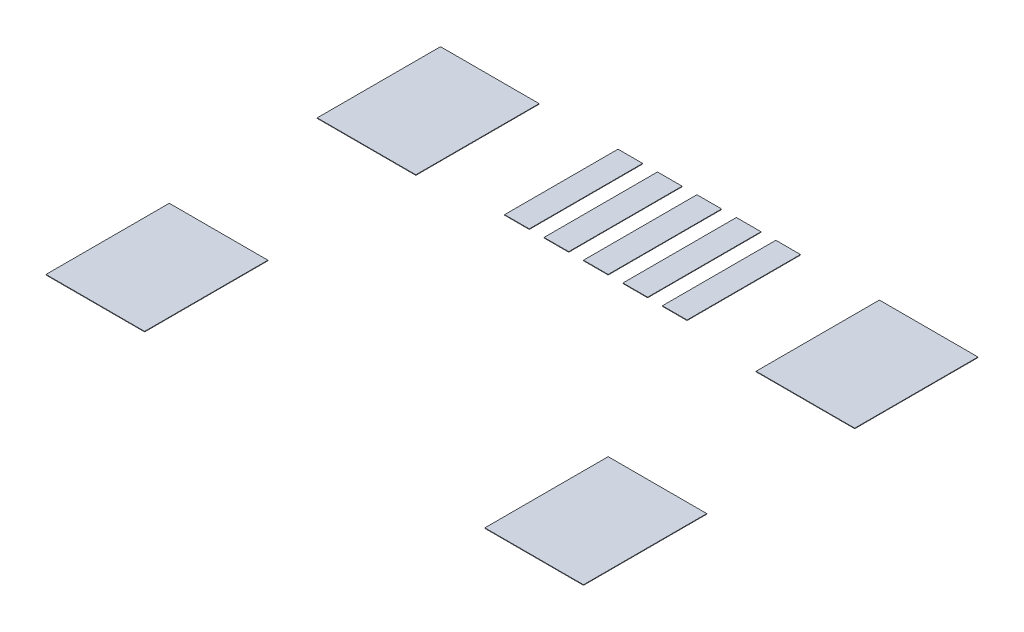
from build123d import *

# Parameters (mm, degrees)
SKETCH1_W             = 2
SKETCH1_H             = 2.5
BOSS_EXTRUDE1_DEPTH   = 0.01
BOSS_EXTRUDE1_2_DEPTH = 0.01
BOSS_EXTRUDE1_3_DEPTH = 0.01
BOSS_EXTRUDE1_4_DEPTH = 0.01
SKETCH1_W_2           = 0.5
SKETCH1_H_2           = 2.3
BOSS_EXTRUDE1_5_DEPTH = 0.01
BOSS_EXTRUDE1_6_DEPTH = 0.01
BOSS_EXTRUDE1_7_DEPTH = 0.01
BOSS_EXTRUDE1_8_DEPTH = 0.01
BOSS_EXTRUDE1_9_DEPTH = 0.01


with BuildPart() as part:
    # Sketch1 → Boss-Extrude1 (new body)
    with BuildSketch(Plane(origin=(0, 0, 0), x_dir=(1, 0, 0), z_dir=(0, 1, 0))):
        with Locations((-4.45, 6.75)):
            Rectangle(SKETCH1_W, SKETCH1_H)
    extrude(amount=-BOSS_EXTRUDE1_DEPTH)


with BuildPart() as body_2:
    # Sketch1 → Boss-Extrude1 2 (new body)
    with BuildSketch(Plane(origin=(0, 0, 0), x_dir=(1, 0, 0), z_dir=(0, 1, 0))):
        with Locations((-4.45, 1.25)):
            Rectangle(SKETCH1_W, SKETCH1_H)
    extrude(amount=-BOSS_EXTRUDE1_2_DEPTH)


with BuildPart() as body_3:
    # Sketch1 → Boss-Extrude1 3 (new body)
    with BuildSketch(Plane(origin=(0, 0, 0), x_dir=(1, 0, 0), z_dir=(0, 1, 0))):
        with Locations((4.45, 6.75)):
            Rectangle(SKETCH1_W, SKETCH1_H)
    extrude(amount=-BOSS_EXTRUDE1_3_DEPTH)


with BuildPart() as body_4:
    # Sketch1 → Boss-Extrude1 4 (new body)
    with BuildSketch(Plane(origin=(0, 0, 0), x_dir=(1, 0, 0), z_dir=(0, 1, 0))):
        with Locations((4.45, 1.25)):
            Rectangle(SKETCH1_W, SKETCH1_H)
    extrude(amount=-BOSS_EXTRUDE1_4_DEPTH)


with BuildPart() as body_5:
    # Sketch1 → Boss-Extrude1 5 (new body)
    with BuildSketch(Plane(origin=(0, 0, 0), x_dir=(1, 0, 0), z_dir=(0, 1, 0))):
        with Locations((-1.6, 6.85)):
            Rectangle(SKETCH1_W_2, SKETCH1_H_2)
    extrude(amount=-BOSS_EXTRUDE1_5_DEPTH)


with BuildPart() as body_6:
    # Sketch1 → Boss-Extrude1 6 (new body)
    with BuildSketch(Plane(origin=(0, 0, 0), x_dir=(1, 0, 0), z_dir=(0, 1, 0))):
        with Locations((-0.8, 6.85)):
            Rectangle(SKETCH1_W_2, SKETCH1_H_2)
    extrude(amount=-BOSS_EXTRUDE1_6_DEPTH)


with BuildPart() as body_7:
    # Sketch1 → Boss-Extrude1 7 (new body)
    with BuildSketch(Plane(origin=(0, 0, 0), x_dir=(1, 0, 0), z_dir=(0, 1, 0))):
        with Locations((0, 6.85)):
            Rectangle(SKETCH1_W_2, SKETCH1_H_2)
    extrude(amount=-BOSS_EXTRUDE1_7_DEPTH)


with BuildPart() as body_8:
    # Sketch1 → Boss-Extrude1 8 (new body)
    with BuildSketch(Plane(origin=(0, 0, 0), x_dir=(1, 0, 0), z_dir=(0, 1, 0))):
        with Locations((0.8, 6.85)):
            Rectangle(SKETCH1_W_2, SKETCH1_H_2)
    extrude(amount=-BOSS_EXTRUDE1_8_DEPTH)


with BuildPart() as body_9:
    # Sketch1 → Boss-Extrude1 9 (new body)
    with BuildSketch(Plane(origin=(0, 0, 0), x_dir=(1, 0, 0), z_dir=(0, 1, 0))):
        with Locations((1.6, 6.85)):
            Rectangle(SKETCH1_W_2, SKETCH1_H_2)
    extrude(amount=-BOSS_EXTRUDE1_9_DEPTH)


solid = Compound([part.part, body_2.part, body_3.part, body_4.part, body_5.part, body_6.part, body_7.part, body_8.part, body_9.part])
